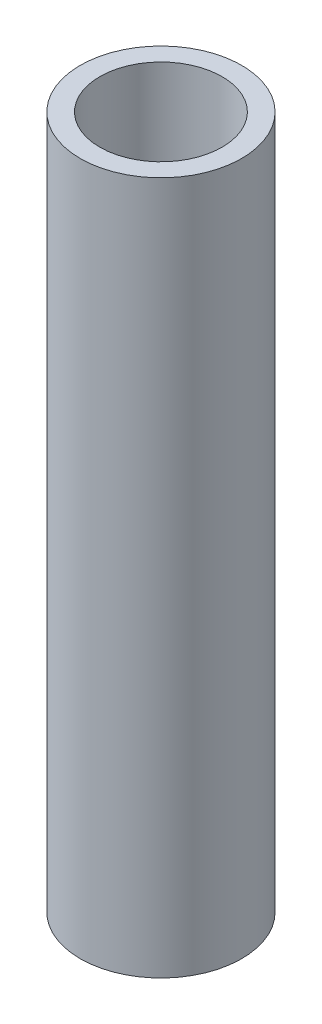
from build123d import *

# Parameters (mm, degrees)
SKETCH1_R           = 12.573
SKETCH1_R_2         = 9.525
BOSS_EXTRUDE1_DEPTH = 107.95


with BuildPart() as part:
    # Sketch1 → Boss-Extrude1 (new body)
    with BuildSketch(Plane(origin=(0, 0, 0), x_dir=(1, 0, 0), z_dir=(0, 1, 0))):
        Circle(SKETCH1_R)
        Circle(SKETCH1_R_2, mode=Mode.SUBTRACT)
    extrude(amount=BOSS_EXTRUDE1_DEPTH)


solid = part.part
